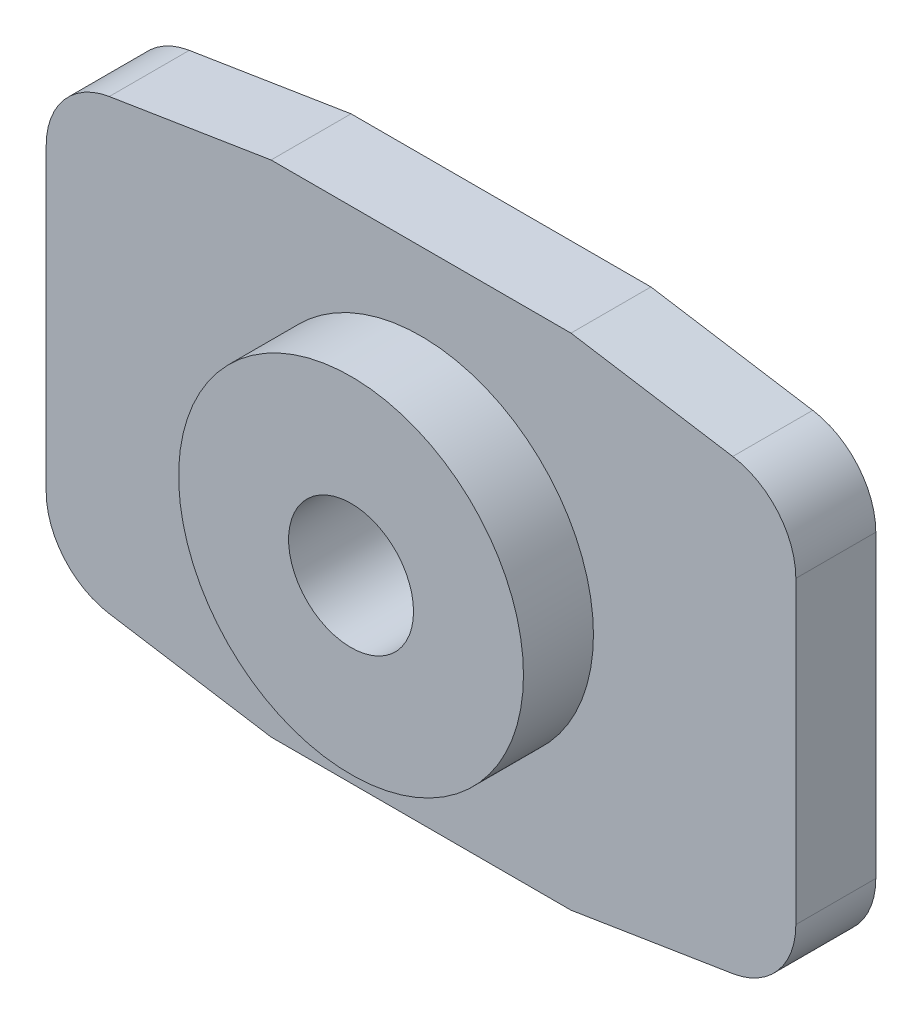
from build123d import *

# Parameters (mm, degrees)
BOSS_EXTRUDE1_DEPTH   = 1.6
SKETCH2_R             = 3.45
BOSS_EXTRUDE2_DEPTH   = 1.4
M3X0_5_TAPPED_HOLE1_D = 2.5


with BuildPart() as part:
    # Sketch1 → Boss-Extrude1 (new body)
    with BuildSketch(Plane.XY):
        with BuildLine():
            Line((-6.237396753, 4.481095129), (-3, 5))
            Line((-3, 5), (3, 5))
            Line((3, 5), (6.237396753, 4.481095129))
            ThreePointArc((6.237396753, 4.481095129), (7.141511088, 3.973114811), (7.5, 3))
            Line((7.5, 3), (7.5, -3))
            ThreePointArc((7.5, -3), (7.141511088, -3.973114811), (6.237396753, -4.481095129))
            Line((6.237396753, -4.481095129), (3, -5))
            Line((3, -5), (-3, -5))
            Line((-3, -5), (-6.237396753, -4.481095129))
            ThreePointArc((-6.237396753, -4.481095129), (-7.141511088, -3.973114811), (-7.5, -3))
            Line((-7.5, -3), (-7.5, 3))
            ThreePointArc((-7.5, 3), (-7.141511088, 3.973114811), (-6.237396753, 4.481095129))
        make_face()
    extrude(amount=BOSS_EXTRUDE1_DEPTH)

    # Sketch2 → Boss-Extrude2 (add)
    with BuildSketch(Plane.XY.offset(1.6)):
        Circle(SKETCH2_R)
    extrude(amount=BOSS_EXTRUDE2_DEPTH)

    # M3x0.5 Tapped Hole1 (through all)
    with Locations(Plane.XY.offset(3)):
        with Locations((0, 0)):
            Hole(M3X0_5_TAPPED_HOLE1_D / 2)


solid = part.part
